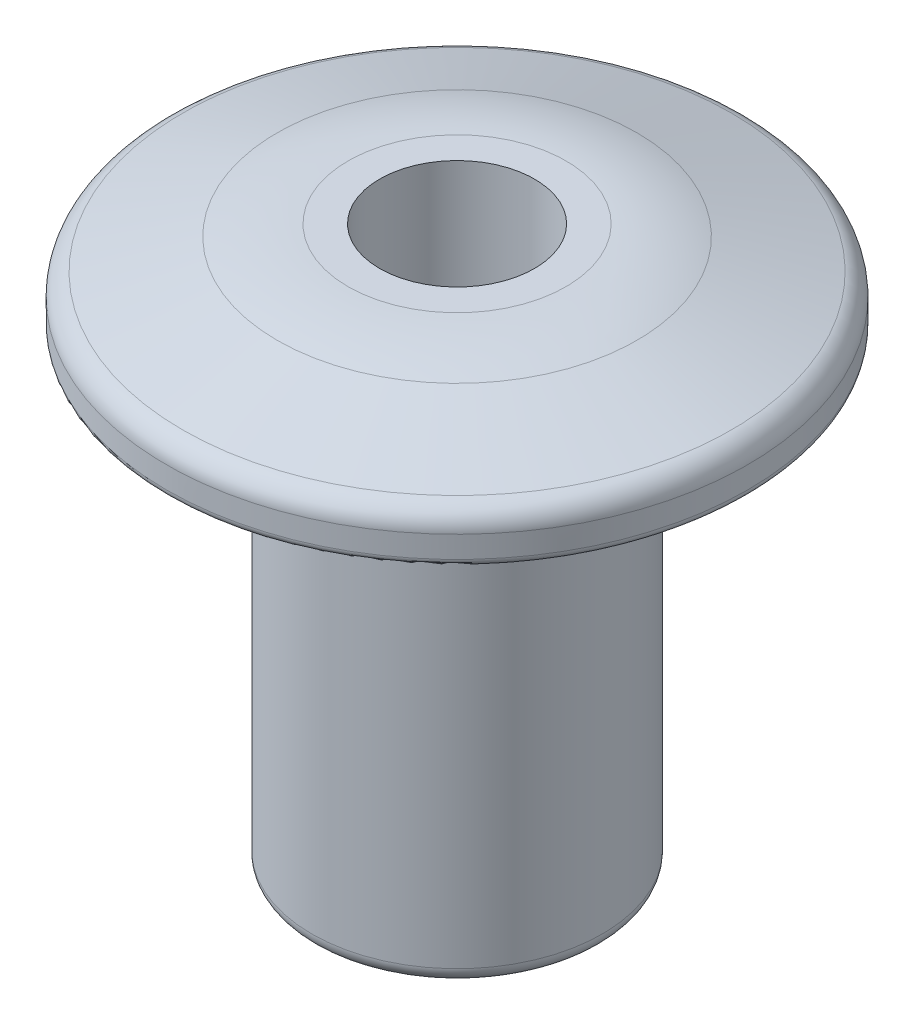
from build123d import *

# Parameters (mm, degrees)
SKETCH1_R           = 2.38125
BOSS_EXTRUDE1_DEPTH = 7.62
SKETCH2_R           = 4.7625
BOSS_EXTRUDE2_DEPTH = 1.524
FILLET1_R           = 0.254
FILLET2_R           = 0.381
FILLET3_R           = 0.127
FILLET4_R           = 3.81
SKETCH4_R           = 1.27
CUT_EXTRUDE1_DEPTH  = 2.54
FILLET5_R           = 0.635


with BuildPart() as part:
    # Sketch1 → Boss-Extrude1 (new body)
    with BuildSketch(Plane(origin=(0, 0, 0), x_dir=(1, 0, 0), z_dir=(0, 1, 0))):
        Circle(SKETCH1_R)
    extrude(amount=BOSS_EXTRUDE1_DEPTH)

    # Sketch2 → Boss-Extrude2 (add)
    with BuildSketch(Plane(origin=(0, 7.62, 0), x_dir=(1, 0, 0), z_dir=(0, 1, 0))):
        Circle(SKETCH2_R)
    extrude(amount=BOSS_EXTRUDE2_DEPTH)

    # Fillet1
    fillet1_edges = [part.edges().sort_by_distance(p)[0] for p in [
        (-2.38125, 0, 0),
    ]]
    fillet(fillet1_edges, radius=FILLET1_R)

    # Sketch3 → Cut-Revolve1 (revolve, cut)
    with BuildSketch(Plane(origin=(0, 0, 0), x_dir=(0, 0, -1), z_dir=(1, 0, 0))):
        Polygon((-2.38125, 9.144), (-4.7625, 8.382), (-4.7625, 9.144), align=None)
    revolve(axis=Axis((0, 9.144, 0), (0, -1, 0)), mode=Mode.SUBTRACT)

    # Fillet2
    fillet2_edges = [part.edges().sort_by_distance(p)[0] for p in [
        (3.367596045, 8.382, 3.367596045),
    ]]
    fillet(fillet2_edges, radius=FILLET2_R)

    # Fillet3
    fillet3_edges = [part.edges().sort_by_distance(p)[0] for p in [
        (-4.7625, 7.62, 0),
    ]]
    fillet(fillet3_edges, radius=FILLET3_R)

    # Fillet4
    fillet4_edges = [part.edges().sort_by_distance(p)[0] for p in [
        (0, 9.144, -2.38125),
    ]]
    fillet(fillet4_edges, radius=FILLET4_R)

    # Sketch4 → Cut-Extrude1 (cut)
    with BuildSketch(Plane(origin=(0, 9.144, 0), x_dir=(1, 0, 0), z_dir=(0, 1, 0))):
        Circle(SKETCH4_R)
    extrude(amount=-CUT_EXTRUDE1_DEPTH, mode=Mode.SUBTRACT)

    # Fillet5
    fillet5_edges = [part.edges().sort_by_distance(p)[0] for p in [
        (-1.27, 6.604, 0),
    ]]
    fillet(fillet5_edges, radius=FILLET5_R)


solid = part.part
